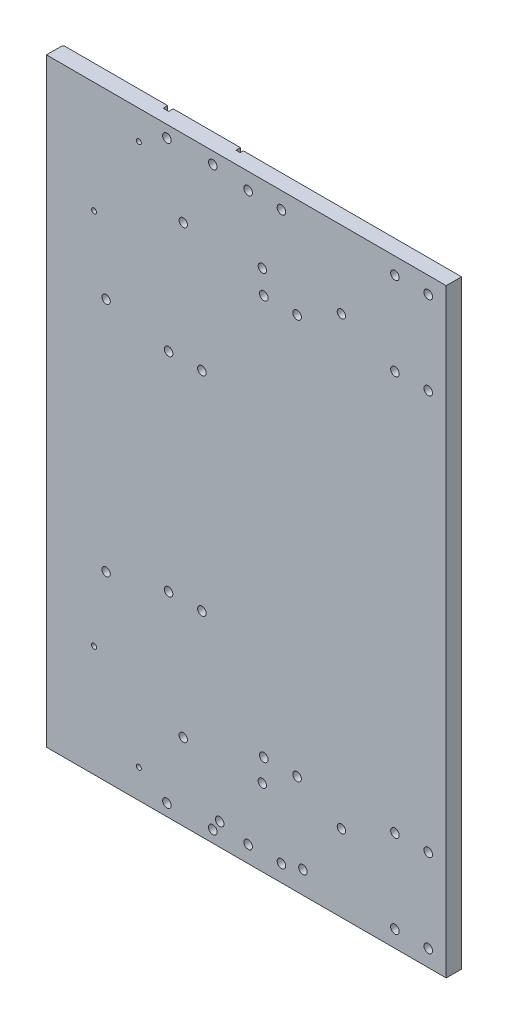
from build123d import *

# Parameters (mm, degrees)
SKETCH1_W                             = 304.8
SKETCH1_H                             = 457.2
EXTRUDE1_DEPTH                        = 12.7
F_5_16_18_TAPPED_HOLE1_D              = 6.5278
F_5_16_18_TAPPED_HOLE1_CSINK_D        = 9.2075
F_5_16_18_TAPPED_HOLE1_CSINK_ANGLE    = 90
CUT_EXTRUDE_THIN1_DEPTH               = 6
CUT_EXTRUDE1_DEPTH                    = 6
F_10_24_TAPPED_HOLE1_D                = 3.7973
F_10_24_TAPPED_HOLE1_CSINK_D          = 6.096
F_10_24_TAPPED_HOLE1_CSINK_ANGLE      = 90
FILLET1_R                             = 3.175
FILLET1_OF_MIRROR3_R                  = 3.175
F_5_16_18_TAPPED_HOLE2_D              = 6.5278
F_5_16_18_TAPPED_HOLE2_DEPTH          = 32.4612
F_5_16_18_TAPPED_HOLE2_CSINK_D        = 9.2075
F_5_16_18_TAPPED_HOLE2_CSINK_ANGLE    = 90
F_5_16_18_TAPPED_HOLE2_TIP            = 1.961148974
F_5_16_18_TAPPED_HOLE3_D              = 6.5278
F_5_16_18_TAPPED_HOLE3_CSINK_D        = 9.2075
F_5_16_18_TAPPED_HOLE3_CSINK_ANGLE    = 90
F_5_16_18_TAPPED_HOLE4_D              = 6.5278
F_5_16_18_TAPPED_HOLE4_DEPTH          = 32.4612
F_5_16_18_TAPPED_HOLE4_CSINK_D        = 9.2075
F_5_16_18_TAPPED_HOLE4_CSINK_ANGLE    = 90
F_5_16_18_TAPPED_HOLE4_TIP            = 1.961148974
F_5_16_18_TAPPED_HOLE5_D              = 6.5278
F_5_16_18_TAPPED_HOLE5_DEPTH          = 32.4612
F_5_16_18_TAPPED_HOLE5_CSINK_D        = 9.2075
F_5_16_18_TAPPED_HOLE5_CSINK_ANGLE    = 90
F_5_16_18_TAPPED_HOLE5_TIP            = 1.961148974
F_1_4_0_25_DIAMETER_HOLE3_D           = 6.35
F_1_4_0_25_DIAMETER_HOLE3_CSINK_D     = 7.112
F_1_4_0_25_DIAMETER_HOLE3_CSINK_ANGLE = 90
F_5_16_18_TAPPED_HOLE6_D              = 6.5278
F_5_16_18_TAPPED_HOLE6_CSINK_D        = 9.2075
F_5_16_18_TAPPED_HOLE6_CSINK_ANGLE    = 90
SKETCH26_W                            = 3.17754
SKETCH26_H                            = 10.587500034
CUT_EXTRUDE2_DEPTH                    = 3.429
SKETCH27_W                            = 4.17754
SKETCH27_H                            = 10.587500034
CUT_EXTRUDE3_DEPTH                    = 3.429
FILLET2_R                             = 1.5875
CHAMFER1_SIZE                         = 1.016


with BuildPart() as part:
    # Sketch1 → Extrude1 (new body)
    with BuildSketch(Plane.XY):
        Rectangle(SKETCH1_W, SKETCH1_H)
    extrude(amount=EXTRUDE1_DEPTH)

    # 5/16-18 Tapped Hole1 (through all)
    with Locations(Plane(origin=(1.36398, 215.9, 0), x_dir=(-1, 0, 0), z_dir=(0, 0, -1))):
        with Locations((0, 0), (-25.4, 0)):
            f_5_16_18_tapped_hole1 = CounterSinkHole(F_5_16_18_TAPPED_HOLE1_D / 2, F_5_16_18_TAPPED_HOLE1_CSINK_D / 2, counter_sink_angle=F_5_16_18_TAPPED_HOLE1_CSINK_ANGLE)

    # Mirror2: 5/16-18 Tapped Hole1 across plane
    add(f_5_16_18_tapped_hole1.mirror(Plane.ZX), mode=Mode.SUBTRACT)

    # Sketch10 → Cut-Extrude-Thin1 (cut)
    with BuildSketch(Plane(origin=(0, 0, 0), x_dir=(-1, 0, 0), z_dir=(0, 0, -1))):
        Polygon((54.545443401, -197.467193268), (99.189352724, -221.70685829), (104.037285729, -212.778076425), (59.393376405, -188.538411404), align=None)
    cut_extrude_thin1 = extrude(amount=-CUT_EXTRUDE_THIN1_DEPTH, mode=Mode.SUBTRACT)

    # Sketch11 → Cut-Extrude1 (cut)
    with BuildSketch(Plane(origin=(0, 0, 0), x_dir=(-1, 0, 0), z_dir=(0, 0, -1))):
        Polygon((88.683375634, -134.592943573), (93.531308638, -125.664161708), (138.175217961, -149.90382673), (133.327284957, -158.832608594), align=None)
        Polygon((54.545443401, -197.467193268), (99.189352724, -221.70685829), (104.037285729, -212.778076425), (59.393376405, -188.538411404), align=None)
    cut_extrude1 = extrude(amount=-CUT_EXTRUDE1_DEPTH, mode=Mode.SUBTRACT)

    # #10-24 Tapped Hole1 (through all)
    with Locations(Plane(origin=(0, 0, 6), x_dir=(-1, 0, 0), z_dir=(0, 0, -1))):
        with Locations((81.969999124, -206.577014748), (116.107931357, -143.702765053)):
            f_10_24_tapped_hole1 = CounterSinkHole(F_10_24_TAPPED_HOLE1_D / 2, F_10_24_TAPPED_HOLE1_CSINK_D / 2, counter_sink_angle=F_10_24_TAPPED_HOLE1_CSINK_ANGLE)

    # Fillet1
    fillet1_edges = [part.edges().sort_by_distance(p)[0] for p in [
        (-99.189352724, -221.70685829, 3),
        (-54.545443401, -197.467193268, 3),
        (-59.393376405, -188.538411404, 3),
        (-104.037285729, -212.778076425, 3),
        (-133.327284957, -158.832608594, 3),
        (-88.683375634, -134.592943573, 3),
        (-93.531308638, -125.664161708, 3),
        (-138.175217961, -149.90382673, 3),
    ]]
    fillet(fillet1_edges, radius=FILLET1_R)

    # Mirror3: Cut-Extrude-Thin1, Cut-Extrude1, #10-24 Tapped Hole1 across plane
    add(cut_extrude_thin1.mirror(Plane.ZX), mode=Mode.SUBTRACT)
    add(cut_extrude1.mirror(Plane.ZX), mode=Mode.SUBTRACT)
    add(f_10_24_tapped_hole1.mirror(Plane.ZX), mode=Mode.SUBTRACT)

    # Fillet1 of Mirror3
    fillet1_of_mirror3_edges = [part.edges().sort_by_distance(p)[0] for p in [
        (-99.189352724, 221.70685829, 3),
        (-54.545443401, 197.467193268, 3),
        (-59.393376405, 188.538411404, 3),
        (-104.037285729, 212.778076425, 3),
        (-133.327284957, 158.832608594, 3),
        (-88.683375634, 134.592943573, 3),
        (-93.531308638, 125.664161708, 3),
        (-138.175217961, 149.90382673, 3),
    ]]
    fillet(fillet1_of_mirror3_edges, radius=FILLET1_OF_MIRROR3_R)

    # 5/16-18 Tapped Hole2
    with Locations(Plane(origin=(0, 0, 0), x_dir=(-1, 0, 0), z_dir=(0, 0, -1))):
        with Locations((-43.18, -211.6), (20.32, -211.6)):
            CounterSinkHole(F_5_16_18_TAPPED_HOLE2_D / 2, F_5_16_18_TAPPED_HOLE2_CSINK_D / 2, depth=F_5_16_18_TAPPED_HOLE2_DEPTH, counter_sink_angle=F_5_16_18_TAPPED_HOLE2_CSINK_ANGLE)
            with Locations((0, 0, -(F_5_16_18_TAPPED_HOLE2_DEPTH + F_5_16_18_TAPPED_HOLE2_TIP / 2))):  # 118° drill point
                Cone(0, F_5_16_18_TAPPED_HOLE2_D / 2, F_5_16_18_TAPPED_HOLE2_TIP, mode=Mode.SUBTRACT)

    # 5/16-18 Tapped Hole3 (through all)
    with Locations(Plane(origin=(0, 0, 0), x_dir=(-1, 0, 0), z_dir=(0, 0, -1))):
        with Locations((-113.3, 215.9), (-138.7, 215.9), (-113.3, 152.4), (-138.7, 152.4), (-113.3, -152.4), (-138.7, -152.4), (-113.3, -215.9), (-138.7, -215.9)):
            CounterSinkHole(F_5_16_18_TAPPED_HOLE3_D / 2, F_5_16_18_TAPPED_HOLE3_CSINK_D / 2, counter_sink_angle=F_5_16_18_TAPPED_HOLE3_CSINK_ANGLE)

    # 5/16-18 Tapped Hole4
    with Locations(Plane(origin=(0, 0, 0), x_dir=(-1, 0, 0), z_dir=(0, 0, -1))):
        with Locations((-38.7, 152.4), (-13.3, 152.4), (-38.7, -152.4), (-13.3, -152.4)):
            CounterSinkHole(F_5_16_18_TAPPED_HOLE4_D / 2, F_5_16_18_TAPPED_HOLE4_CSINK_D / 2, depth=F_5_16_18_TAPPED_HOLE4_DEPTH, counter_sink_angle=F_5_16_18_TAPPED_HOLE4_CSINK_ANGLE)
            with Locations((0, 0, -(F_5_16_18_TAPPED_HOLE4_DEPTH + F_5_16_18_TAPPED_HOLE4_TIP / 2))):  # 118° drill point
                Cone(0, F_5_16_18_TAPPED_HOLE4_D / 2, F_5_16_18_TAPPED_HOLE4_TIP, mode=Mode.SUBTRACT)

    # 5/16-18 Tapped Hole5
    with Locations(Plane(origin=(0, 0, 0), x_dir=(-1, 0, 0), z_dir=(0, 0, -1))):
        with Locations((33.8966, 79.375), (59.2966, 79.375), (33.8966, -79.375), (59.2966, -79.375)):
            CounterSinkHole(F_5_16_18_TAPPED_HOLE5_D / 2, F_5_16_18_TAPPED_HOLE5_CSINK_D / 2, depth=F_5_16_18_TAPPED_HOLE5_DEPTH, counter_sink_angle=F_5_16_18_TAPPED_HOLE5_CSINK_ANGLE)
            with Locations((0, 0, -(F_5_16_18_TAPPED_HOLE5_DEPTH + F_5_16_18_TAPPED_HOLE5_TIP / 2))):  # 118° drill point
                Cone(0, F_5_16_18_TAPPED_HOLE5_D / 2, F_5_16_18_TAPPED_HOLE5_TIP, mode=Mode.SUBTRACT)

    # 1/4 (0.25) Diameter Hole3 (through all)
    with Locations(Plane(origin=(0, 0, 0), x_dir=(-1, 0, 0), z_dir=(0, 0, -1))):
        with Locations((106.9213, 90), (106.9213, -90), (48.1203, 170), (48.1203, -170), (-12.1793, 170), (-72.4789, 170), (-12.1793, -170), (-72.4789, -170)):
            CounterSinkHole(F_1_4_0_25_DIAMETER_HOLE3_D / 2, F_1_4_0_25_DIAMETER_HOLE3_CSINK_D / 2, counter_sink_angle=F_1_4_0_25_DIAMETER_HOLE3_CSINK_ANGLE)

    # 5/16-18 Tapped Hole6 (through all)
    with Locations(Plane(origin=(0, 0, 0), x_dir=(-1, 0, 0), z_dir=(0, 0, -1))):
        with Locations((25.5657, -219.6), (60.5657, -219.6)):
            f_5_16_18_tapped_hole6 = CounterSinkHole(F_5_16_18_TAPPED_HOLE6_D / 2, F_5_16_18_TAPPED_HOLE6_CSINK_D / 2, counter_sink_angle=F_5_16_18_TAPPED_HOLE6_CSINK_ANGLE)

    # Sketch26 → Cut-Extrude2 (cut)
    with BuildSketch(Plane(origin=(0, 0, 0), x_dir=(-1, 0, 0), z_dir=(0, 0, -1))):
        with Locations((15.5657, -223.306249983)):
            Rectangle(SKETCH26_W, SKETCH26_H)
        with Locations((70.5657, -223.306249983)):
            Rectangle(SKETCH26_W, SKETCH26_H)
    cut_extrude2 = extrude(amount=-CUT_EXTRUDE2_DEPTH, mode=Mode.SUBTRACT)

    # Sketch27 → Cut-Extrude3 (cut)
    with BuildSketch(Plane(origin=(0, 0, 0), x_dir=(-1, 0, 0), z_dir=(0, 0, -1))):
        with Locations((70.5657, -223.306249983)):
            Rectangle(SKETCH27_W, SKETCH27_H)
    cut_extrude3 = extrude(amount=-CUT_EXTRUDE3_DEPTH, mode=Mode.SUBTRACT)

    # Mirror4: 5/16-18 Tapped Hole6, Cut-Extrude2, Cut-Extrude3 across plane
    add(f_5_16_18_tapped_hole6.mirror(Plane.ZX), mode=Mode.SUBTRACT)
    add(cut_extrude2.mirror(Plane.ZX), mode=Mode.SUBTRACT)
    add(cut_extrude3.mirror(Plane.ZX), mode=Mode.SUBTRACT)

    # Fillet2
    fillet2_edges = [part.edges().sort_by_distance(p)[0] for p in [
        (-13.97693, -218.012499966, 1.7145),
        (-17.15447, -218.012499966, 1.7145),
        (-68.47693, -218.012499966, 1.7145),
        (-72.65447, -218.012499966, 1.7145),
        (-13.97693, 218.012499966, 1.7145),
        (-17.15447, 218.012499966, 1.7145),
        (-72.65447, 218.012499966, 1.7145),
        (-68.47693, 218.012499966, 1.7145),
    ]]
    fillet(fillet2_edges, radius=FILLET2_R)

    # Chamfer1
    chamfer1_edges = [part.edges().sort_by_distance(p)[0] for p in [
        (-112.527235, -228.6, 0),
        (-152.4, 0, 0),
        (69.211535, 228.6, 0),
        (152.4, 0, 0),
    ]]
    chamfer(chamfer1_edges, length=CHAMFER1_SIZE)


solid = part.part
